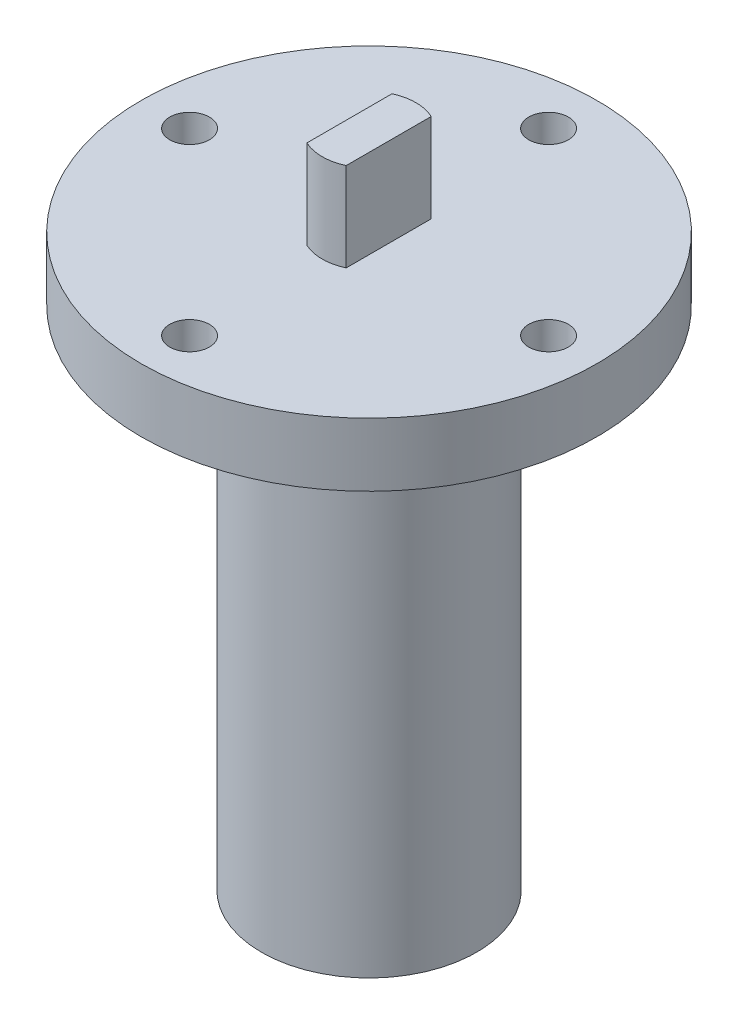
from build123d import *

# Parameters (mm, degrees)
SKETCH1_R                           = 22.86
BOSS_EXTRUDE1_DEPTH                 = 6.35
BOSS_EXTRUDE2_DEPTH                 = 8.89
SKETCH3_R                           = 10.795
BOSS_EXTRUDE3_DEPTH                 = 50.8
CHAMFER1_SIZE                       = 3.81
F_5_32_0_15625_DIAMETER_HOLE1_D     = 3.96875
F_5_32_0_15625_DIAMETER_HOLE1_DEPTH = 6.351
CIRPATTERN1_COUNT                   = 4


with BuildPart() as part:
    # Sketch1 → Boss-Extrude1 (new body)
    with BuildSketch(Plane(origin=(0, 0, 0), x_dir=(1, 0, 0), z_dir=(0, 1, 0))):
        Circle(SKETCH1_R)
    extrude(amount=BOSS_EXTRUDE1_DEPTH)

    # Sketch2 → Boss-Extrude2 (add)
    with BuildSketch(Plane(origin=(0, 6.35, 0), x_dir=(1, 0, 0), z_dir=(0, 1, 0))):
        with BuildLine():
            Line((1.9685, -4.266803107), (1.9685, 4.266803107))
            ThreePointArc((1.9685, 4.266803107), (0, 4.699), (-1.9685, 4.266803107))
            Line((-1.9685, 4.266803107), (-1.9685, -4.266803107))
            ThreePointArc((-1.9685, -4.266803107), (0, -4.699), (1.9685, -4.266803107))
        make_face()
    extrude(amount=BOSS_EXTRUDE2_DEPTH)

    # Sketch3 → Boss-Extrude3 (add)
    with BuildSketch(Plane.XZ):
        Circle(SKETCH3_R)
    extrude(amount=BOSS_EXTRUDE3_DEPTH)

    # Chamfer1
    chamfer1_edges = [part.edges().sort_by_distance(p)[0] for p in [
        (-10.795, 0, 0),
    ]]
    chamfer(chamfer1_edges, length=CHAMFER1_SIZE)

    # 5/32 (0.15625) Diameter Hole1
    with Locations(Plane(origin=(0, 6.35, 0), x_dir=(1, 0, 0), z_dir=(0, 1, 0))):
        with Locations((0, 18)):
            f_5_32_0_15625_diameter_hole1 = Hole(F_5_32_0_15625_DIAMETER_HOLE1_D / 2, depth=F_5_32_0_15625_DIAMETER_HOLE1_DEPTH)

    # CirPattern1: 5/32 (0.15625) Diameter Hole1 ×4 about axis
    cirpattern1_axis = Axis((0, 0, 0), (0, 1, 0))
    for i in range(1, CIRPATTERN1_COUNT):
        add(f_5_32_0_15625_diameter_hole1.rotate(cirpattern1_axis, i * 360 / CIRPATTERN1_COUNT), mode=Mode.SUBTRACT)


solid = part.part
